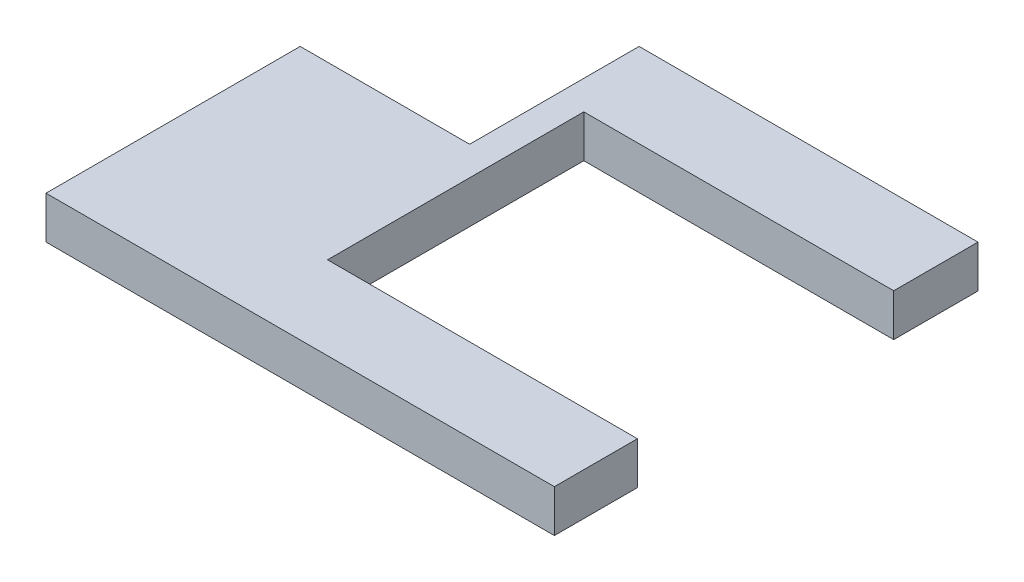
from build123d import *

# Parameters (mm, degrees)
EXTRUDE_1_DEPTH = 10


with BuildPart() as part:
    # Эскиз1 → Бобышка-Вытянуть1 (new body)
    with BuildSketch(Plane(origin=(0, 0, 0), x_dir=(1, 0, 0), z_dir=(0, 1, 0))):
        Polygon((0, 0), (120, 0), (120, 19.605344545), (46.85083046, 19.605344545), (46.85083046, 80.103552046), (120, 80.103552046), (120, 100), (40, 100), (40, 60), (0, 60), align=None)
    extrude(amount=EXTRUDE_1_DEPTH)


solid = part.part
